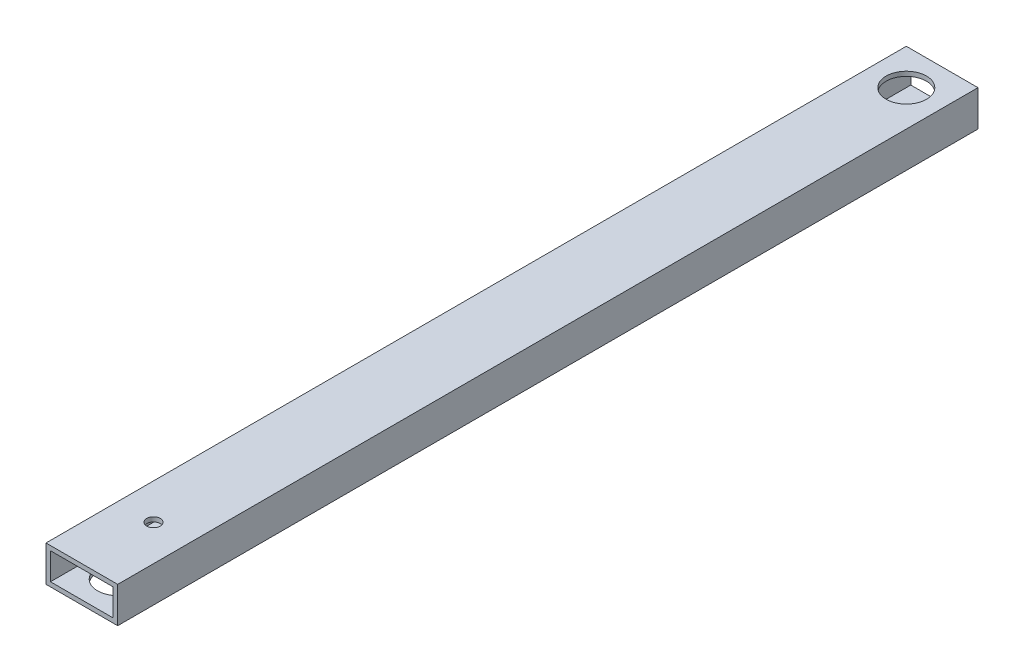
from build123d import *

# Parameters (mm, degrees)
SKETCH1_W           = 50.8
SKETCH1_H           = 25.4
BOSS_EXTRUDE1_DEPTH = 609.6
SKETCH2_W           = 44.45
SKETCH2_H           = 19.05
CUT_EXTRUDE1_DEPTH  = 635
SKETCH6_R           = 14.2875
CUT_EXTRUDE5_DEPTH  = 25.4
SKETCH7_R           = 14.2875
CUT_EXTRUDE6_DEPTH  = 3.175
SKETCH8_R           = 4.7625
CUT_EXTRUDE7_DEPTH  = 25.4


with BuildPart() as part:
    # Sketch1 → Boss-Extrude1 (new body)
    with BuildSketch(Plane.XY):
        with Locations((25.4, 12.7)):
            Rectangle(SKETCH1_W, SKETCH1_H)
    extrude(amount=BOSS_EXTRUDE1_DEPTH)

    # Sketch2 → Cut-Extrude1 (cut)
    with BuildSketch(Plane(origin=(0, 0, 0), x_dir=(-1, 0, 0), z_dir=(0, 0, -1))):
        with Locations((-25.4, 12.7)):
            Rectangle(SKETCH2_W, SKETCH2_H)
    extrude(amount=-CUT_EXTRUDE1_DEPTH, mode=Mode.SUBTRACT)

    # Sketch6 → Cut-Extrude5 (cut)
    with BuildSketch(Plane(origin=(0, 25.4, 0), x_dir=(1, 0, 0), z_dir=(0, 1, 0))):
        with Locations((25.4, -25.4)):
            Circle(SKETCH6_R)
    extrude(amount=-CUT_EXTRUDE5_DEPTH, mode=Mode.SUBTRACT)

    # Sketch7 → Cut-Extrude6 (cut)
    with BuildSketch(Plane.XZ):
        with Locations((25.4, 584.2)):
            Circle(SKETCH7_R)
    extrude(amount=-CUT_EXTRUDE6_DEPTH, mode=Mode.SUBTRACT)

    # Sketch8 → Cut-Extrude7 (cut)
    with BuildSketch(Plane(origin=(0, 25.4, 0), x_dir=(1, 0, 0), z_dir=(0, 1, 0))):
        with Locations((25.4, -558.8)):
            Circle(SKETCH8_R)
    extrude(amount=-CUT_EXTRUDE7_DEPTH, mode=Mode.SUBTRACT)


solid = part.part
